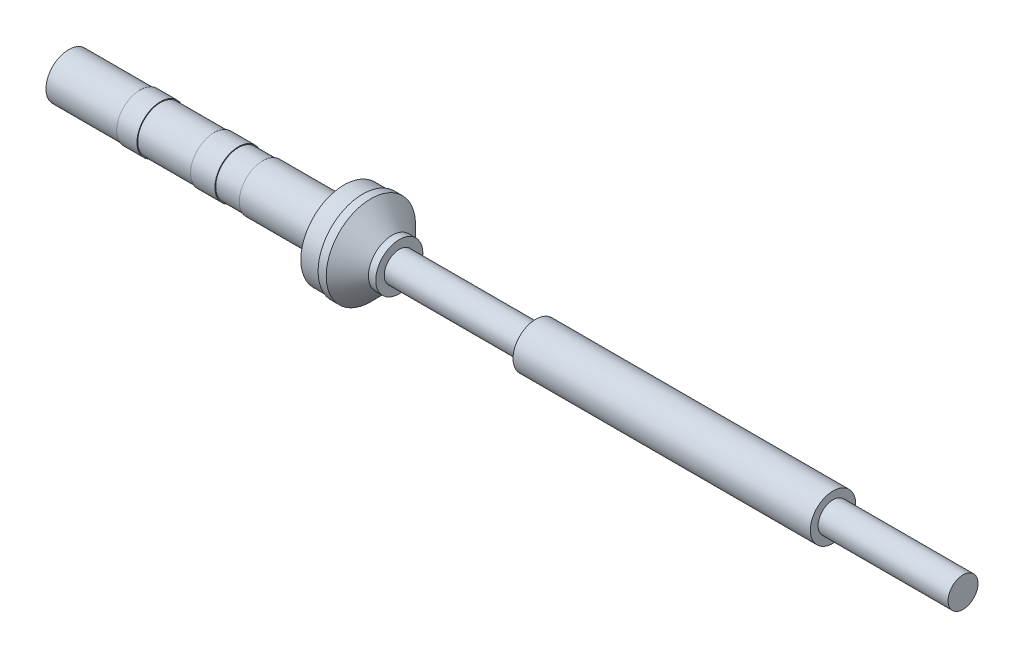
from build123d import *

# Parameters (mm, degrees)
SKETCH2_R           = 2.794474829
CUT_EXTRUDE1_DEPTH  = 28
SKETCH3_R           = 2.794474829
BOSS_EXTRUDE1_DEPTH = 28


with BuildPart() as part:
    # Sketch1 → Revolve1 (revolve)
    with BuildSketch(Plane(origin=(0, 0, 0), x_dir=(1, 0, 0), z_dir=(0, 1, 0))):
        Polygon((23.900000378, -2.895873106), (33.900000155, -2.895873106), (33.900000155, -5.320860504), (36.200001836, -5.320860504), (36.200001836, -5.494461861), (37.200000137, -5.494461861), (39.799999446, -2.895873106), (40.699999779, -2.895873106), (40.699999779, -1.845926362), (57.500001043, -1.845926362), (57.500001043, -2.794474829), (94.099998474, -2.794474829), (94.099998474, -1.845926362), (110.100001097, -1.845926362), (110.100001097, 0), (0, 0), (0, -2.794474829), (8.799999952, -2.794474829), (8.799999952, -2.895873106), (11.300000362, -2.895873106), (11.300000362, -2.794474829), (17.899999395, -2.794474829), (17.899999395, -2.895873106), (20.899999887, -2.895873106), (20.899999887, -2.794474829), (23.900000378, -2.794474829), align=None)
    revolve(axis=Axis((0, 0, 0), (1, 0, 0)))

    # Sketch2 → Cut-Extrude1 (cut)
    with BuildSketch(Plane.ZY):
        Circle(SKETCH2_R)
    extrude(amount=-CUT_EXTRUDE1_DEPTH, mode=Mode.SUBTRACT)


with BuildPart() as body_2:
    # Sketch3 → Boss-Extrude1 (new body)
    with BuildSketch(Plane(origin=(0, 0, 0), x_dir=(0, 0, -1), z_dir=(1, 0, 0))):
        Circle(SKETCH3_R)
    extrude(amount=BOSS_EXTRUDE1_DEPTH)


solid = Compound([part.part, body_2.part])
